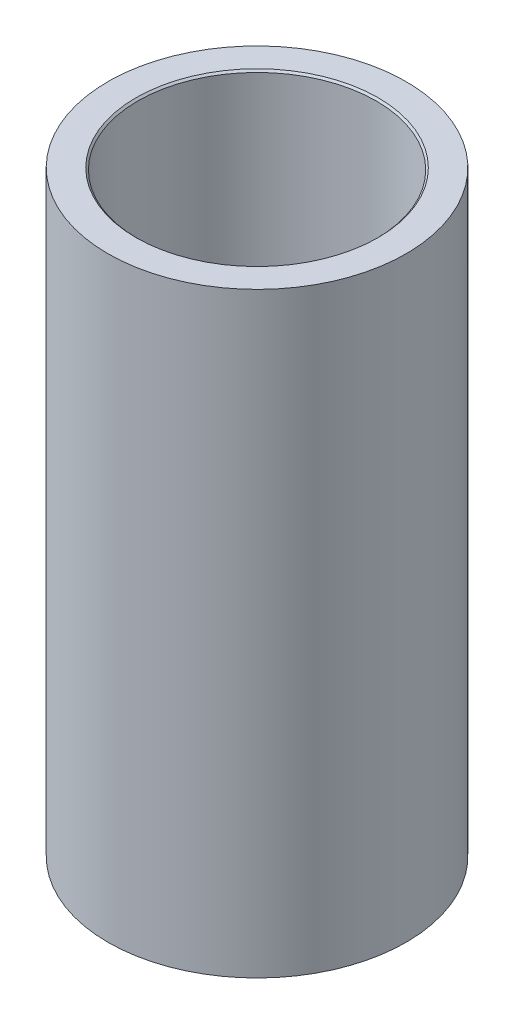
from build123d import *

# Parameters (mm, degrees)
ESQUISSE1_R                = 2
BOSS_EXTRU_1_DEPTH         = 8
D_GAGEMENT_M32_D           = 3.2
D_GAGEMENT_M32_DEPTH       = 8
D_GAGEMENT_M32_CSINK_D     = 3.25
D_GAGEMENT_M32_CSINK_ANGLE = 90


with BuildPart() as part:
    # Esquisse1 → Boss.-Extru.1 (new body)
    with BuildSketch(Plane(origin=(0, 0, 0), x_dir=(1, 0, 0), z_dir=(0, 1, 0))):
        Circle(ESQUISSE1_R)
    extrude(amount=BOSS_EXTRU_1_DEPTH)

    # Dégagement M32
    with Locations(Plane(origin=(0, 8, 0), x_dir=(1, 0, 0), z_dir=(0, 1, 0))):
        with Locations((0, 0)):
            CounterSinkHole(D_GAGEMENT_M32_D / 2, D_GAGEMENT_M32_CSINK_D / 2, depth=D_GAGEMENT_M32_DEPTH, counter_sink_angle=D_GAGEMENT_M32_CSINK_ANGLE)


solid = part.part
